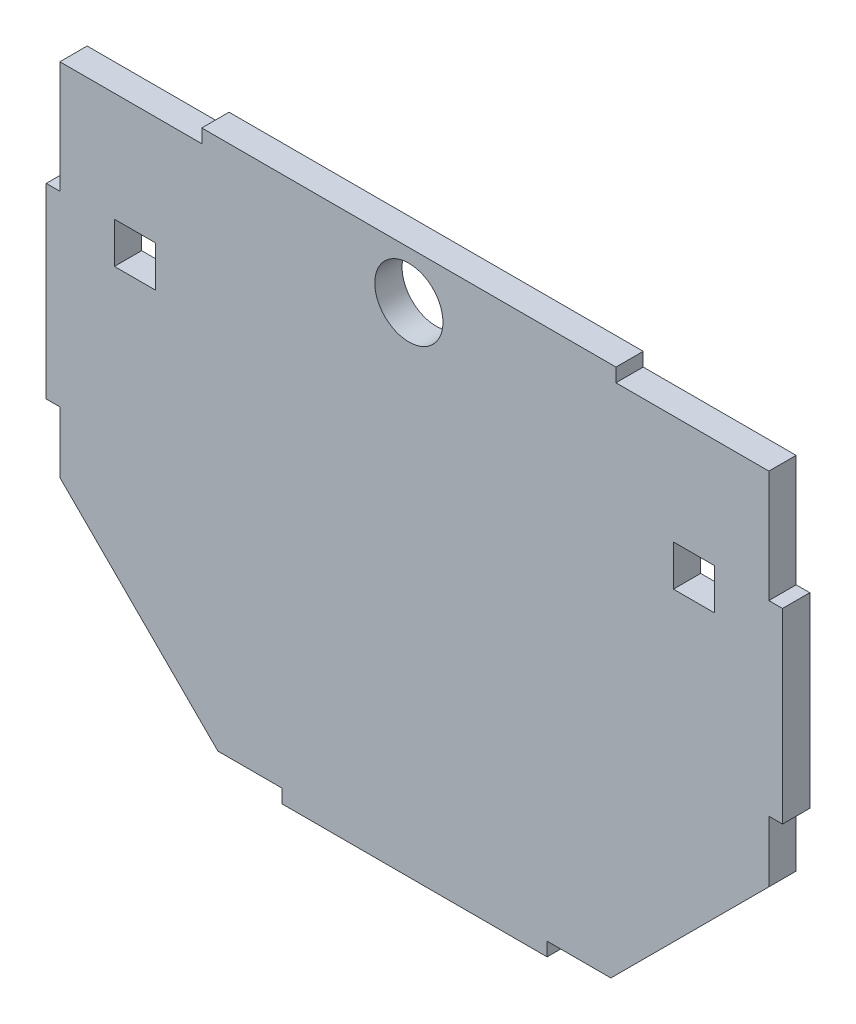
from build123d import *

# Parameters (mm, degrees)
BOSS_EXTRUDE1_DEPTH = 12.7
SKETCH2_R           = 15.875
SKETCH2_W           = 19.05
SKETCH2_H           = 19.05
CUT_EXTRUDE1_DEPTH  = 13.7


with BuildPart() as part:
    # Sketch1 → Boss-Extrude1 (new body)
    with BuildSketch(Plane.XY):
        Polygon((424.715446324, 892.207843626), (424.715446324, 920.715652439), (418.365446324, 920.715652439), (418.365446324, 1007.691853389), (424.715446324, 1007.691853389), (424.715446324, 1059.919118431), (490.806723979, 1059.919118431), (490.806723979, 1066.269118431), (683.70003755, 1066.269118431), (683.70003755, 1059.919118431), (754.915446324, 1059.919118431), (754.915446324, 1007.691853389), (761.265446324, 1007.691853389), (761.265446324, 920.715652439), (754.915446324, 920.715652439), (754.915446324, 892.207843626), (681.331146762, 818.667305174), (651.634447679, 818.667305174), (651.634447679, 812.317305174), (528.064815274, 812.317305174), (528.064815274, 818.667305174), (498.299745887, 818.667305174), align=None)
    extrude(amount=BOSS_EXTRUDE1_DEPTH)

    # Sketch2 → Cut-Extrude1 (cut, through all)
    with BuildSketch(Plane.XY.offset(12.7)):
        with Locations((587.253380764, 1044.044118431)):
            Circle(SKETCH2_R)
        with Locations((459.640446324, 999.594118431)):
            Rectangle(SKETCH2_W, SKETCH2_H)
        with Locations((719.990446324, 999.594118431)):
            Rectangle(SKETCH2_W, SKETCH2_H)
    extrude(amount=-CUT_EXTRUDE1_DEPTH, mode=Mode.SUBTRACT)


solid = part.part
